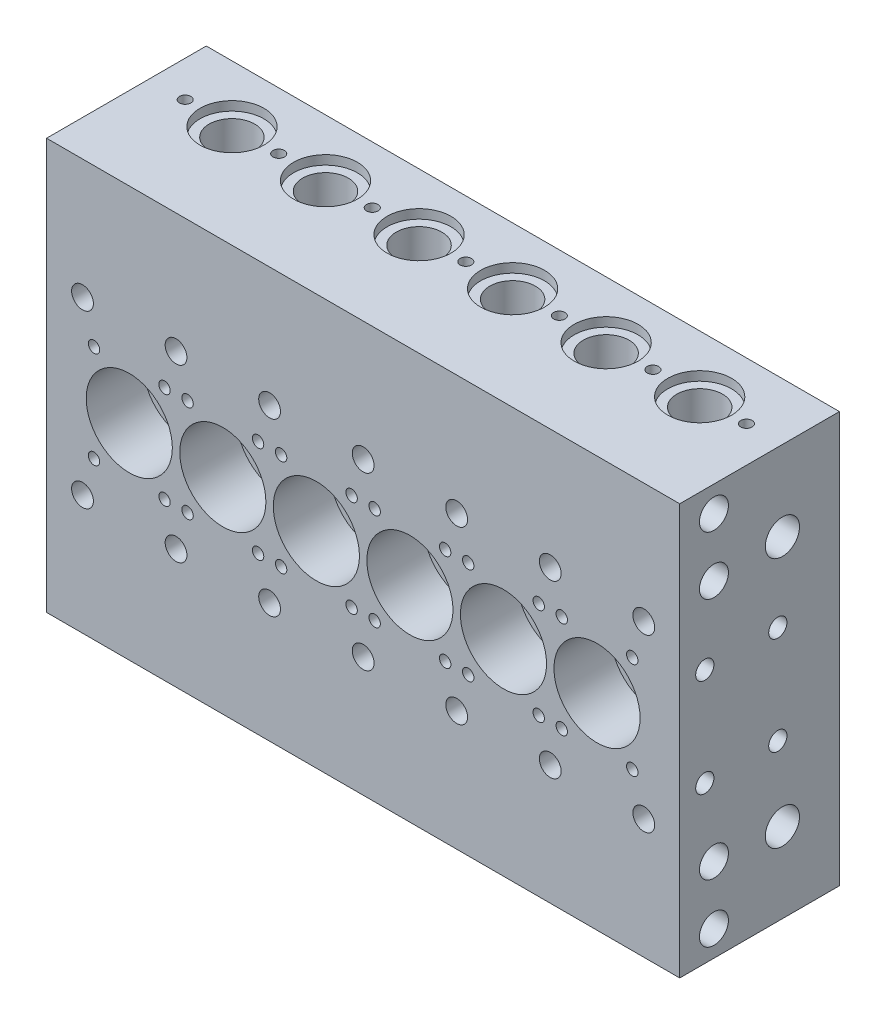
from build123d import *

# Parameters (mm, degrees)
SKETCH1_W                  = 555
SKETCH1_H                  = 360
BOSS_EXTRUDE1_DEPTH        = 140
SKETCH2_R                  = 22.5
CUT_EXTRUDE1_DEPTH         = 140
SKETCH3_R                  = 37.75
CUT_EXTRUDE2_DEPTH         = 50
SKETCH4_R                  = 28
CUT_EXTRUDE3_DEPTH         = 8
LPATTERN1_COUNT            = 6
LPATTERN1_PITCH            = 82
SKETCH5_R                  = 5
CUT_EXTRUDE4_DEPTH         = 20
LPATTERN2_COUNT            = 2
LPATTERN2_PITCH            = 61.8
LPATTERN2_COUNT_DIR2       = 2
LPATTERN2_PITCH_DIR2       = 84.9
LPATTERN3_COUNT            = 6
LPATTERN3_PITCH            = 82
LPATTERN3_COPY_1_SKETCH_R  = 5
LPATTERN3_COPY_1_DEPTH     = 20
LPATTERN3_COPY_2_SKETCH_R  = 5
LPATTERN3_COPY_2_DEPTH     = 20
LPATTERN3_COPY_3_SKETCH_R  = 5
LPATTERN3_COPY_3_DEPTH     = 20
LPATTERN3_COPY_4_SKETCH_R  = 5
LPATTERN3_COPY_4_DEPTH     = 20
LPATTERN3_COPY_5_SKETCH_R  = 5
LPATTERN3_COPY_5_DEPTH     = 20
LPATTERN3_COPY_6_SKETCH_R  = 5
LPATTERN3_COPY_6_DEPTH     = 20
LPATTERN3_COPY_7_SKETCH_R  = 5
LPATTERN3_COPY_7_DEPTH     = 20
LPATTERN3_COPY_8_SKETCH_R  = 5
LPATTERN3_COPY_8_DEPTH     = 20
LPATTERN3_COPY_9_SKETCH_R  = 5
LPATTERN3_COPY_9_DEPTH     = 20
LPATTERN3_COPY_10_SKETCH_R = 5
LPATTERN3_COPY_10_DEPTH    = 20
LPATTERN3_COPY_11_SKETCH_R = 5
LPATTERN3_COPY_11_DEPTH    = 20
LPATTERN3_COPY_12_SKETCH_R = 5
LPATTERN3_COPY_12_DEPTH    = 20
LPATTERN3_COPY_13_SKETCH_R = 5
LPATTERN3_COPY_13_DEPTH    = 20
LPATTERN3_COPY_14_SKETCH_R = 5
LPATTERN3_COPY_14_DEPTH    = 20
LPATTERN3_COPY_15_SKETCH_R = 5
LPATTERN3_COPY_15_DEPTH    = 20
SKETCH6_R                  = 9.55
CUT_EXTRUDE5_DEPTH         = 140
LPATTERN4_COUNT            = 2
LPATTERN4_PITCH            = 150
LPATTERN4_COUNT_DIR2       = 7
LPATTERN4_PITCH_DIR2       = 82
SKETCH7_R                  = 12.7
SKETCH7_R_2                = 15
CUT_EXTRUDE6_DEPTH         = 556
SKETCH8_R                  = 8
CUT_EXTRUDE7_DEPTH         = 23
LPATTERN5_COUNT            = 2
LPATTERN5_PITCH            = 64
LPATTERN5_COUNT_DIR2       = 2
LPATTERN5_PITCH_DIR2       = 86
SKETCH9_R                  = 8
CUT_EXTRUDE8_DEPTH         = 23
LPATTERN6_COUNT            = 2
LPATTERN6_PITCH            = 64
LPATTERN6_COUNT_DIR2       = 2
LPATTERN6_PITCH_DIR2       = 86
SKETCH10_R                 = 28
CUT_EXTRUDE9_DEPTH         = 8
SKETCH11_R                 = 20
CUT_EXTRUDE10_DEPTH        = 139
SKETCH12_R                 = 5
CUT_EXTRUDE11_DEPTH        = 20
SKETCH13_R                 = 28
CUT_EXTRUDE12_DEPTH        = 8
SKETCH14_R                 = 20
CUT_EXTRUDE13_DEPTH        = 139
SKETCH15_R                 = 16
CUT_EXTRUDE14_DEPTH        = 20
LPATTERN7_COUNT            = 6
LPATTERN7_PITCH            = 82
SKETCH16_R                 = 5
CUT_EXTRUDE15_DEPTH        = 20
LPATTERN8_COUNT            = 7
LPATTERN8_PITCH            = 82
SKETCH17_R                 = 5
CUT_EXTRUDE16_DEPTH        = 20
LPATTERN9_COUNT            = 7
LPATTERN9_PITCH            = 82


with BuildPart() as part:
    # Sketch1 → Boss-Extrude1 (new body)
    with BuildSketch(Plane.XY):
        Rectangle(SKETCH1_W, SKETCH1_H)
    extrude(amount=BOSS_EXTRUDE1_DEPTH)

    # Sketch2 → Cut-Extrude1 (cut)
    with BuildSketch(Plane.XY.offset(140)):
        with Locations((-205, 0)):
            Circle(SKETCH2_R)
    cut_extrude1 = extrude(amount=-CUT_EXTRUDE1_DEPTH, mode=Mode.SUBTRACT)

    # Sketch3 → Cut-Extrude2 (cut)
    with BuildSketch(Plane.XY.offset(140)):
        with Locations((-205, 0)):
            Circle(SKETCH3_R)
    cut_extrude2 = extrude(amount=-CUT_EXTRUDE2_DEPTH, mode=Mode.SUBTRACT)

    # Sketch4 → Cut-Extrude3 (cut)
    with BuildSketch(Plane(origin=(0, 0, 0), x_dir=(-1, 0, 0), z_dir=(0, 0, -1))):
        with Locations((205, 0)):
            Circle(SKETCH4_R)
    cut_extrude3 = extrude(amount=-CUT_EXTRUDE3_DEPTH, mode=Mode.SUBTRACT)

    # LPattern1: Cut-Extrude1, Cut-Extrude2, Cut-Extrude3 ×6
    with Locations(*[(i * LPATTERN1_PITCH, 0, 0) for i in range(1, LPATTERN1_COUNT)]):
        add(cut_extrude1, mode=Mode.SUBTRACT)
        add(cut_extrude2, mode=Mode.SUBTRACT)
        add(cut_extrude3, mode=Mode.SUBTRACT)

    # Sketch5 → Cut-Extrude4 (cut)
    with BuildSketch(Plane.XY.offset(140)):
        with Locations((-235.9, 42.5)):
            Circle(SKETCH5_R)
    cut_extrude4 = extrude(amount=-CUT_EXTRUDE4_DEPTH, mode=Mode.SUBTRACT)

    # LPattern2: Cut-Extrude4 2 × 2
    with Locations(*[(i * LPATTERN2_PITCH, -j * LPATTERN2_PITCH_DIR2, 0) for i in range(LPATTERN2_COUNT) for j in range(LPATTERN2_COUNT_DIR2) if (i, j) != (0, 0)]):
        add(cut_extrude4, mode=Mode.SUBTRACT)

    # LPattern3: Cut-Extrude4 ×6
    with Locations(*[(i * LPATTERN3_PITCH, 0, 0) for i in range(1, LPATTERN3_COUNT)]):
        add(cut_extrude4, mode=Mode.SUBTRACT)

    # LPattern3 copy 1 sketch → LPattern3 copy 1 (cut)
    with BuildSketch(Plane(origin=(82, -84.9, 140), x_dir=(1, 0, 0), z_dir=(0, 0, 1))):
        with Locations((-235.9, 42.5)):
            Circle(LPATTERN3_COPY_1_SKETCH_R)
    extrude(amount=-LPATTERN3_COPY_1_DEPTH, mode=Mode.SUBTRACT)

    # LPattern3 copy 2 sketch → LPattern3 copy 2 (cut)
    with BuildSketch(Plane(origin=(164, -84.9, 140), x_dir=(1, 0, 0), z_dir=(0, 0, 1))):
        with Locations((-235.9, 42.5)):
            Circle(LPATTERN3_COPY_2_SKETCH_R)
    extrude(amount=-LPATTERN3_COPY_2_DEPTH, mode=Mode.SUBTRACT)

    # LPattern3 copy 3 sketch → LPattern3 copy 3 (cut)
    with BuildSketch(Plane(origin=(246, -84.9, 140), x_dir=(1, 0, 0), z_dir=(0, 0, 1))):
        with Locations((-235.9, 42.5)):
            Circle(LPATTERN3_COPY_3_SKETCH_R)
    extrude(amount=-LPATTERN3_COPY_3_DEPTH, mode=Mode.SUBTRACT)

    # LPattern3 copy 4 sketch → LPattern3 copy 4 (cut)
    with BuildSketch(Plane(origin=(328, -84.9, 140), x_dir=(1, 0, 0), z_dir=(0, 0, 1))):
        with Locations((-235.9, 42.5)):
            Circle(LPATTERN3_COPY_4_SKETCH_R)
    extrude(amount=-LPATTERN3_COPY_4_DEPTH, mode=Mode.SUBTRACT)

    # LPattern3 copy 5 sketch → LPattern3 copy 5 (cut)
    with BuildSketch(Plane(origin=(410, -84.9, 140), x_dir=(1, 0, 0), z_dir=(0, 0, 1))):
        with Locations((-235.9, 42.5)):
            Circle(LPATTERN3_COPY_5_SKETCH_R)
    extrude(amount=-LPATTERN3_COPY_5_DEPTH, mode=Mode.SUBTRACT)

    # LPattern3 copy 6 sketch → LPattern3 copy 6 (cut)
    with BuildSketch(Plane(origin=(143.8, 0, 140), x_dir=(1, 0, 0), z_dir=(0, 0, 1))):
        with Locations((-235.9, 42.5)):
            Circle(LPATTERN3_COPY_6_SKETCH_R)
    extrude(amount=-LPATTERN3_COPY_6_DEPTH, mode=Mode.SUBTRACT)

    # LPattern3 copy 7 sketch → LPattern3 copy 7 (cut)
    with BuildSketch(Plane(origin=(225.8, 0, 140), x_dir=(1, 0, 0), z_dir=(0, 0, 1))):
        with Locations((-235.9, 42.5)):
            Circle(LPATTERN3_COPY_7_SKETCH_R)
    extrude(amount=-LPATTERN3_COPY_7_DEPTH, mode=Mode.SUBTRACT)

    # LPattern3 copy 8 sketch → LPattern3 copy 8 (cut)
    with BuildSketch(Plane(origin=(307.8, 0, 140), x_dir=(1, 0, 0), z_dir=(0, 0, 1))):
        with Locations((-235.9, 42.5)):
            Circle(LPATTERN3_COPY_8_SKETCH_R)
    extrude(amount=-LPATTERN3_COPY_8_DEPTH, mode=Mode.SUBTRACT)

    # LPattern3 copy 9 sketch → LPattern3 copy 9 (cut)
    with BuildSketch(Plane(origin=(389.8, 0, 140), x_dir=(1, 0, 0), z_dir=(0, 0, 1))):
        with Locations((-235.9, 42.5)):
            Circle(LPATTERN3_COPY_9_SKETCH_R)
    extrude(amount=-LPATTERN3_COPY_9_DEPTH, mode=Mode.SUBTRACT)

    # LPattern3 copy 10 sketch → LPattern3 copy 10 (cut)
    with BuildSketch(Plane(origin=(471.8, 0, 140), x_dir=(1, 0, 0), z_dir=(0, 0, 1))):
        with Locations((-235.9, 42.5)):
            Circle(LPATTERN3_COPY_10_SKETCH_R)
    extrude(amount=-LPATTERN3_COPY_10_DEPTH, mode=Mode.SUBTRACT)

    # LPattern3 copy 11 sketch → LPattern3 copy 11 (cut)
    with BuildSketch(Plane(origin=(143.8, -84.9, 140), x_dir=(1, 0, 0), z_dir=(0, 0, 1))):
        with Locations((-235.9, 42.5)):
            Circle(LPATTERN3_COPY_11_SKETCH_R)
    extrude(amount=-LPATTERN3_COPY_11_DEPTH, mode=Mode.SUBTRACT)

    # LPattern3 copy 12 sketch → LPattern3 copy 12 (cut)
    with BuildSketch(Plane(origin=(225.8, -84.9, 140), x_dir=(1, 0, 0), z_dir=(0, 0, 1))):
        with Locations((-235.9, 42.5)):
            Circle(LPATTERN3_COPY_12_SKETCH_R)
    extrude(amount=-LPATTERN3_COPY_12_DEPTH, mode=Mode.SUBTRACT)

    # LPattern3 copy 13 sketch → LPattern3 copy 13 (cut)
    with BuildSketch(Plane(origin=(307.8, -84.9, 140), x_dir=(1, 0, 0), z_dir=(0, 0, 1))):
        with Locations((-235.9, 42.5)):
            Circle(LPATTERN3_COPY_13_SKETCH_R)
    extrude(amount=-LPATTERN3_COPY_13_DEPTH, mode=Mode.SUBTRACT)

    # LPattern3 copy 14 sketch → LPattern3 copy 14 (cut)
    with BuildSketch(Plane(origin=(389.8, -84.9, 140), x_dir=(1, 0, 0), z_dir=(0, 0, 1))):
        with Locations((-235.9, 42.5)):
            Circle(LPATTERN3_COPY_14_SKETCH_R)
    extrude(amount=-LPATTERN3_COPY_14_DEPTH, mode=Mode.SUBTRACT)

    # LPattern3 copy 15 sketch → LPattern3 copy 15 (cut)
    with BuildSketch(Plane(origin=(471.8, -84.9, 140), x_dir=(1, 0, 0), z_dir=(0, 0, 1))):
        with Locations((-235.9, 42.5)):
            Circle(LPATTERN3_COPY_15_SKETCH_R)
    extrude(amount=-LPATTERN3_COPY_15_DEPTH, mode=Mode.SUBTRACT)

    # Sketch6 → Cut-Extrude5 (cut)
    with BuildSketch(Plane.XY.offset(140)):
        with Locations((-246, 75)):
            Circle(SKETCH6_R)
    cut_extrude5 = extrude(amount=-CUT_EXTRUDE5_DEPTH, mode=Mode.SUBTRACT)

    # LPattern4: Cut-Extrude5 2 × 7
    with Locations(*[(j * LPATTERN4_PITCH_DIR2, -i * LPATTERN4_PITCH, 0) for i in range(LPATTERN4_COUNT) for j in range(LPATTERN4_COUNT_DIR2) if (i, j) != (0, 0)]):
        add(cut_extrude5, mode=Mode.SUBTRACT)

    # Sketch7 → Cut-Extrude6 (cut, through all)
    with BuildSketch(Plane(origin=(277.5, 0, 0), x_dir=(0, 0, -1), z_dir=(1, 0, 0))):
        with Locations((-110, -157.5)):
            Circle(SKETCH7_R)
        with Locations((-110, -106.5)):
            Circle(SKETCH7_R)
        with Locations((-50, -110)):
            Circle(SKETCH7_R_2)
        with Locations((-110, 157.5)):
            Circle(SKETCH7_R)
        with Locations((-50, 110)):
            Circle(SKETCH7_R_2)
        with Locations((-110, 106.5)):
            Circle(SKETCH7_R)
    extrude(amount=-CUT_EXTRUDE6_DEPTH, mode=Mode.SUBTRACT)

    # Sketch8 → Cut-Extrude7 (cut)
    with BuildSketch(Plane(origin=(277.5, 0, 0), x_dir=(0, 0, -1), z_dir=(1, 0, 0))):
        with Locations((-118, -43)):
            Circle(SKETCH8_R)
    cut_extrude7 = extrude(amount=-CUT_EXTRUDE7_DEPTH, mode=Mode.SUBTRACT)

    # LPattern5: Cut-Extrude7 2 × 2
    with Locations(*[(0, j * LPATTERN5_PITCH_DIR2, -i * LPATTERN5_PITCH) for i in range(LPATTERN5_COUNT) for j in range(LPATTERN5_COUNT_DIR2) if (i, j) != (0, 0)]):
        add(cut_extrude7, mode=Mode.SUBTRACT)

    # Sketch9 → Cut-Extrude8 (cut)
    with BuildSketch(Plane.ZY.offset(277.5)):
        with Locations((118, 43)):
            Circle(SKETCH9_R)
    cut_extrude8 = extrude(amount=-CUT_EXTRUDE8_DEPTH, mode=Mode.SUBTRACT)

    # LPattern6: Cut-Extrude8 2 × 2
    with Locations(*[(0, -j * LPATTERN6_PITCH_DIR2, -i * LPATTERN6_PITCH) for i in range(LPATTERN6_COUNT) for j in range(LPATTERN6_COUNT_DIR2) if (i, j) != (0, 0)]):
        add(cut_extrude8, mode=Mode.SUBTRACT)

    # Sketch10 → Cut-Extrude9 (cut)
    with BuildSketch(Plane(origin=(0, 180, 0), x_dir=(1, 0, 0), z_dir=(0, 1, 0))):
        with Locations((-205, -50)):
            Circle(SKETCH10_R)
    cut_extrude9 = extrude(amount=-CUT_EXTRUDE9_DEPTH, mode=Mode.SUBTRACT)

    # Sketch11 → Cut-Extrude10 (cut)
    with BuildSketch(Plane(origin=(0, 172, 0), x_dir=(1, 0, 0), z_dir=(0, 1, 0))):
        with Locations((-205, -50)):
            Circle(SKETCH11_R)
    cut_extrude10 = extrude(amount=-CUT_EXTRUDE10_DEPTH, mode=Mode.SUBTRACT)

    # Sketch12 → Cut-Extrude11 (cut)
    with BuildSketch(Plane(origin=(0, 33, 0), x_dir=(1, 0, 0), z_dir=(0, 1, 0))):
        with Locations((-205, -50)):
            Circle(SKETCH12_R)
    cut_extrude11 = extrude(amount=-CUT_EXTRUDE11_DEPTH, mode=Mode.SUBTRACT)

    # Sketch13 → Cut-Extrude12 (cut)
    with BuildSketch(Plane.XZ.offset(180)):
        with Locations((-205, 50)):
            Circle(SKETCH13_R)
    cut_extrude12 = extrude(amount=-CUT_EXTRUDE12_DEPTH, mode=Mode.SUBTRACT)

    # Sketch14 → Cut-Extrude13 (cut)
    with BuildSketch(Plane.XZ.offset(172)):
        with Locations((-205, 50)):
            Circle(SKETCH14_R)
    cut_extrude13 = extrude(amount=-CUT_EXTRUDE13_DEPTH, mode=Mode.SUBTRACT)

    # Sketch15 → Cut-Extrude14 (cut)
    with BuildSketch(Plane.XZ.offset(33)):
        with Locations((-205, 50)):
            Circle(SKETCH15_R)
    cut_extrude14 = extrude(amount=-CUT_EXTRUDE14_DEPTH, mode=Mode.SUBTRACT)

    # LPattern7: Cut-Extrude9, Cut-Extrude10, Cut-Extrude11, Cut-Extrude12, Cut-Extrude13, Cut-Extrude14 ×6
    with Locations(*[(i * LPATTERN7_PITCH, 0, 0) for i in range(1, LPATTERN7_COUNT)]):
        add(cut_extrude9, mode=Mode.SUBTRACT)
        add(cut_extrude10, mode=Mode.SUBTRACT)
        add(cut_extrude11, mode=Mode.SUBTRACT)
        add(cut_extrude12, mode=Mode.SUBTRACT)
        add(cut_extrude13, mode=Mode.SUBTRACT)
        add(cut_extrude14, mode=Mode.SUBTRACT)

    # Sketch16 → Cut-Extrude15 (cut)
    with BuildSketch(Plane(origin=(0, 180, 0), x_dir=(1, 0, 0), z_dir=(0, 1, 0))):
        with Locations((-246, -50)):
            Circle(SKETCH16_R)
    cut_extrude15 = extrude(amount=-CUT_EXTRUDE15_DEPTH, mode=Mode.SUBTRACT)

    # LPattern8: Cut-Extrude15 ×7
    with Locations(*[(i * LPATTERN8_PITCH, 0, 0) for i in range(1, LPATTERN8_COUNT)]):
        add(cut_extrude15, mode=Mode.SUBTRACT)

    # Sketch17 → Cut-Extrude16 (cut)
    with BuildSketch(Plane.XZ.offset(180)):
        with Locations((-246, 50)):
            Circle(SKETCH17_R)
    cut_extrude16 = extrude(amount=-CUT_EXTRUDE16_DEPTH, mode=Mode.SUBTRACT)

    # LPattern9: Cut-Extrude16 ×7
    with Locations(*[(i * LPATTERN9_PITCH, 0, 0) for i in range(1, LPATTERN9_COUNT)]):
        add(cut_extrude16, mode=Mode.SUBTRACT)


solid = part.part
